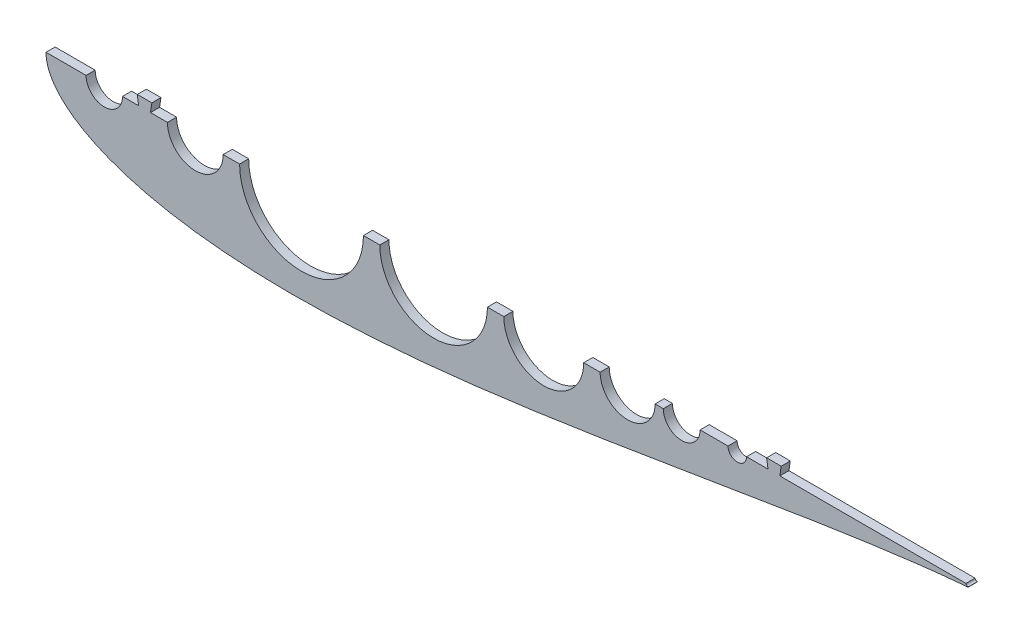
from build123d import *

# Parameters (mm, degrees)
BOSS_EXTRUDE1_DEPTH     = 6.35
CUT_EXTRUDE2_DEPTH      = 1.0000001
CUT_EXTRUDE2_DEPTH_BACK = 7.3500001
SKETCH4_W               = 6.35
SKETCH4_H               = 6.35
BOSS_EXTRUDE2_DEPTH     = 6.35


with BuildPart() as part:
    # Sketch2 → Boss-Extrude1 (new body)
    with BuildSketch(Plane.XY):
        with BuildLine():
            ThreePointArc((642.510849283, -1.582039112), (643.111845681, -1.408373102), (643.599082689, -1.016))
            ThreePointArc((643.599082689, -1.016), (642.269121423, -1.135922533), (641.567082689, 0))
            Line((641.567082689, 0), (473.360965279, 0))
            Line((473.360965279, 0), (460.660965279, 0))
            Line((460.660965279, 0), (123.571, 0))
            ThreePointArc((123.571, 0), (104.14, -19.431), (84.709, 0))
            Line((84.709, 0), (53.34, 0))
            ThreePointArc((53.34, 0), (40.64, -12.7), (27.94, 0))
            Line((27.94, 0), (0, 0))
            add(Edge.make_bspline(
                [(0, 0), (0, -1.007496172), (0.154611582, -3.513796615), (1.106333228, -7.923389435), (3.463136343, -13.420354421), (7.689616489, -19.513207632), (13.932423524, -25.726412106), (22.129107375, -31.731455339), (32.141645239, -37.332204029), (43.82045433, -42.41500246), (57.023709725, -46.912543066), (71.619696083, -50.784752003), (87.485018636, -54.008935199), (104.502313427, -56.574303932), (122.558104573, -58.481758104), (141.542033828, -59.739895824), (161.345829027, -60.366961324), (181.863132616, -60.387506142), (202.989192599, -59.8341217), (224.620860897, -58.745176641), (246.65655865, -57.164603829), (268.996310773, -55.141201012), (291.541767704, -52.727712704), (314.196207315, -49.979843895), (336.86454415, -46.955447457), (359.453314895, -43.713502532), (381.870662856, -40.313266856), (404.02631566, -36.813220545), (425.831595832, -33.270324121), (447.199424328, -29.739007432), (468.044367735, -26.27043606), (488.282710288, -22.911672601), (507.832591566, -19.705111663), (526.614143658, -16.687720753), (544.549749946, -13.890665375), (561.564270734, -11.338919625), (577.585454095, -9.050636147), (592.543922516, -7.037634907), (606.374988512, -5.304428983), (619.014124193, -3.849253664), (630.413817462, -2.663385493), (638.093728429, -1.953546407), (641.993392355, -1.625070631), (642.510849283, -1.582039112)],
                knots=[0.5, 0.5, 0.5, 0.5, 0.502166769, 0.505390167, 0.509655974, 0.514947682, 0.521244711, 0.528520886, 0.536744945, 0.54588136, 0.555890751, 0.566730119, 0.57835299, 0.590709588, 0.603747039, 0.617409572, 0.631638768, 0.646373793, 0.661551658, 0.677107483, 0.692974771, 0.709085713, 0.725371443, 0.741762353, 0.758188398, 0.774579367, 0.790865214, 0.806976332, 0.822843867, 0.838400002, 0.853578262, 0.868313774, 0.882543568, 0.896206835, 0.909245173, 0.92160287, 0.933227116, 0.944068236, 0.954079898, 0.963219316, 0.971447445, 0.978729112, 0.979842958, 0.979842958, 0.979842958, 0.979842958], degree=3))
        make_face()
    extrude(amount=BOSS_EXTRUDE1_DEPTH)

    # Sketch3 → Cut-Extrude2 (cut, two sides)
    with BuildSketch(Plane.XY.offset(6.35)) as cut_extrude2_sk:
        with BuildLine():
            ThreePointArc((221.368346157, 0), (178.184673078, 43.183673078), (135.001, 0))
            Line((135.001, 0), (221.368346157, 0))
        make_face()
        with BuildLine():
            Line((221.368346157, 0), (135.001, 0))
            ThreePointArc((135.001, 0), (178.184673078, -43.183673078), (221.368346157, 0))
        make_face()
        with BuildLine():
            ThreePointArc((307.839599131, 0), (270.318972644, 37.520626487), (232.798346157, 0))
            Line((232.798346157, 0), (307.839599131, 0))
        make_face()
        with BuildLine():
            Line((307.839599131, 0), (232.798346157, 0))
            ThreePointArc((232.798346157, 0), (270.318972644, -37.520626487), (307.839599131, 0))
        make_face()
        with BuildLine():
            ThreePointArc((374.99479385, 0), (347.13219649, 27.862597359), (319.269599131, 0))
            Line((319.269599131, 0), (374.99479385, 0))
        make_face()
        with BuildLine():
            Line((374.99479385, 0), (319.269599131, 0))
            ThreePointArc((319.269599131, 0), (347.13219649, -27.862597359), (374.99479385, 0))
        make_face()
        with BuildLine():
            ThreePointArc((424.77879385, 0), (405.60179385, 19.177), (386.42479385, 0))
            Line((386.42479385, 0), (424.77879385, 0))
        make_face()
        with BuildLine():
            Line((424.77879385, 0), (386.42479385, 0))
            ThreePointArc((386.42479385, 0), (405.60179385, -19.177), (424.77879385, 0))
        make_face()
        with BuildLine():
            ThreePointArc((430.474866123, 0), (443.301866123, -12.827), (456.128866123, 0))
            Line((456.128866123, 0), (430.474866123, 0))
        make_face()
        with BuildLine():
            Line((430.474866123, 0), (456.128866123, 0))
            ThreePointArc((456.128866123, 0), (443.301866123, 12.827), (430.474866123, 0))
        make_face()
        with BuildLine():
            ThreePointArc((475.605534569, 0), (482.082534569, -6.477), (488.559534569, 0))
            Line((488.559534569, 0), (475.605534569, 0))
        make_face()
        with BuildLine():
            Line((475.605534569, 0), (488.559534569, 0))
            ThreePointArc((488.559534569, 0), (482.082534569, 6.477), (475.605534569, 0))
        make_face()
    extrude(amount=CUT_EXTRUDE2_DEPTH, mode=Mode.SUBTRACT)
    extrude(cut_extrude2_sk.sketch, amount=-CUT_EXTRUDE2_DEPTH_BACK, mode=Mode.SUBTRACT)

    # Sketch4 → Boss-Extrude2 (add)
    with BuildSketch(Plane.XY.offset(6.35)):
        Polygon((503.482034569, 0), (504.434534569, 0), (504.434534569, 6.35), (502.529534569, 6.35), align=None)
        with Locations((507.609534569, 3.175)):
            Rectangle(SKETCH4_W, SKETCH4_H)
        Polygon((510.784534569, 0), (511.737034569, 0), (512.689534569, 6.35), (510.784534569, 6.35), align=None)
        Polygon((65.565, 6.35), (63.66, 6.35), (64.6125, 0), (65.565, 0), align=None)
        with Locations((68.74, 3.175)):
            Rectangle(SKETCH4_W, SKETCH4_H)
        Polygon((73.82, 6.35), (71.915, 6.35), (71.915, 0), (72.8675, 0), align=None)
    extrude(amount=-BOSS_EXTRUDE2_DEPTH)


solid = part.part
